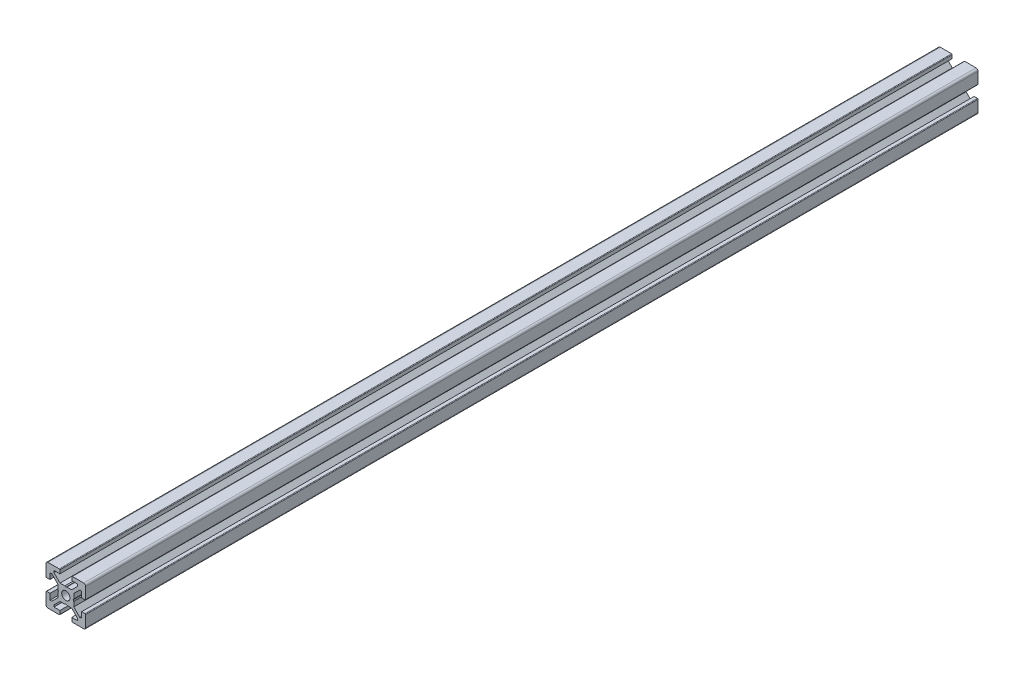
from build123d import *

# Parameters (mm, degrees)
BOSS_EXTRUDE1_DEPTH = 450
SKETCH2_W           = 450
SKETCH2_H           = 2.1


with BuildPart() as part:
    # Sketch1 → Boss-Extrude1 (new body)
    with BuildSketch(Plane.XY):
        with BuildLine():
            Line((-10, 9), (-10, 3.29999995))
            ThreePointArc((-10, 3.29999995), (-9.912132049, 3.087867916), (-9.7, 3))
            Line((-9.7, 3), (-8, 3))
            Line((-8, 3), (-8, 6))
            Line((-8, 6), (-7.060677, 6))
            Line((-7.060677, 6), (-4, 2.93932965))
            Line((-4, 2.93932965), (-4, 0.519615242))
            Line((-4, 0.519615242), (-3.699996283, -6.437e-06))
            Line((-3.699996283, -6.437e-06), (-4, -0.519628117))
            Line((-4, -0.519628117), (-4, -2.93933725))
            Line((-4, -2.93933725), (-7.0606695, -6))
            Line((-7.0606695, -6), (-8, -6))
            Line((-8, -6), (-8, -3))
            Line((-8, -3), (-9.7, -3))
            ThreePointArc((-9.7, -3), (-9.912132049, -3.087867916), (-10, -3.29999995))
            Line((-10, -3.29999995), (-10, -9))
            ThreePointArc((-10, -9), (-9.707106781, -9.707106781), (-9, -10))
            Line((-9, -10), (-3.29999995, -10))
            ThreePointArc((-3.29999995, -10), (-3.087867916, -9.912132049), (-3, -9.7))
            Line((-3, -9.7), (-3, -8))
            Line((-3, -8), (-6, -8))
            Line((-6, -8), (-6, -7.0606515))
            Line((-6, -7.0606515), (-2.9393489, -4))
            Line((-2.9393489, -4), (-0.519615242, -4))
            Line((-0.519615242, -4), (6.437e-06, -3.699996283))
            Line((6.437e-06, -3.699996283), (0.519628117, -4))
            Line((0.519628117, -4), (2.9393227, -4))
            Line((2.9393227, -4), (6, -7.060677))
            Line((6, -7.060677), (6, -8))
            Line((6, -8), (3, -8))
            Line((3, -8), (3, -9.7))
            ThreePointArc((3, -9.7), (3.087867916, -9.912132049), (3.29999995, -10))
            Line((3.29999995, -10), (9, -10))
            ThreePointArc((9, -10), (9.707106781, -9.707106781), (10, -9))
            Line((10, -9), (10, -3.29999995))
            ThreePointArc((10, -3.29999995), (9.912132049, -3.087867916), (9.7, -3))
            Line((9.7, -3), (8, -3))
            Line((8, -3), (8, -6))
            Line((8, -6), (7.0606435, -6))
            Line((7.0606435, -6), (4, -2.9393482))
            Line((4, -2.9393482), (4, -0.519615242))
            Line((4, -0.519615242), (3.699996283, 6.437e-06))
            Line((3.699996283, 6.437e-06), (4, 0.519628117))
            Line((4, 0.519628117), (4, 2.9393401))
            Line((4, 2.9393401), (7.060651, 6))
            Line((7.060651, 6), (8, 6))
            Line((8, 6), (8, 3))
            Line((8, 3), (9.7, 3))
            ThreePointArc((9.7, 3), (9.912132049, 3.087867916), (10, 3.29999995))
            Line((10, 3.29999995), (10, 9))
            ThreePointArc((10, 9), (9.707106781, 9.707106781), (9, 10))
            Line((9, 10), (3.29999995, 10))
            ThreePointArc((3.29999995, 10), (3.087867916, 9.912132049), (3, 9.7))
            Line((3, 9.7), (3, 8))
            Line((3, 8), (6, 8))
            Line((6, 8), (6, 7.060669))
            Line((6, 7.060669), (2.9393308, 4))
            Line((2.9393308, 4), (0.519615242, 4))
            Line((0.519615242, 4), (-6.437e-06, 3.699996283))
            Line((-6.437e-06, 3.699996283), (-0.519628117, 4))
            Line((-0.519628117, 4), (-2.93935655, 4))
            Line((-2.93935655, 4), (-6, 7.0606435))
            Line((-6, 7.0606435), (-6, 8))
            Line((-6, 8), (-3, 8))
            Line((-3, 8), (-3, 9.7))
            ThreePointArc((-3, 9.7), (-3.087867966, 9.912132034), (-3.3, 10))
            Line((-3.3, 10), (-9, 10))
            ThreePointArc((-9, 10), (-9.707106781, 9.707106781), (-10, 9))
        make_face()
    extrude(amount=-BOSS_EXTRUDE1_DEPTH)

    # Sketch2 → Cut-Revolve1 (revolve, cut)
    with BuildSketch(Plane(origin=(0, 0, 0), x_dir=(0, 0, -1), z_dir=(1, 0, 0))):
        with Locations((225, 1.05)):
            Rectangle(SKETCH2_W, SKETCH2_H)
    revolve(axis=Axis((0, 0, -450), (0, 0, 1)), mode=Mode.SUBTRACT)


solid = part.part
